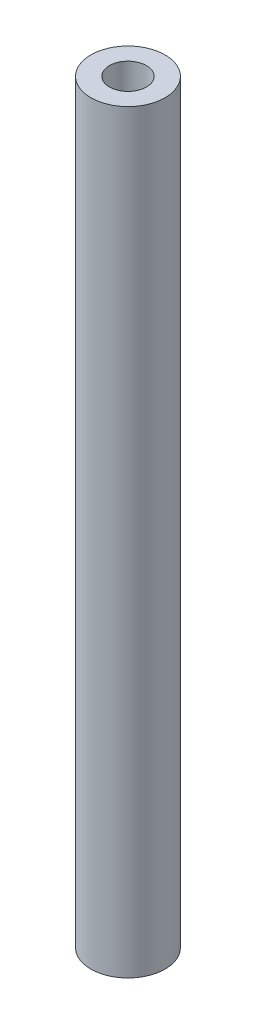
from build123d import *

# Parameters (mm, degrees)
SKETCH1_R           = 3
SKETCH1_R_2         = 1.5
BOSS_EXTRUDE1_DEPTH = 61


with BuildPart() as part:
    # Sketch1 → Boss-Extrude1 (new body)
    with BuildSketch(Plane(origin=(0, 0, 0), x_dir=(1, 0, 0), z_dir=(0, 1, 0))):
        Circle(SKETCH1_R)
        Circle(SKETCH1_R_2, mode=Mode.SUBTRACT)
    extrude(amount=BOSS_EXTRUDE1_DEPTH)


solid = part.part
